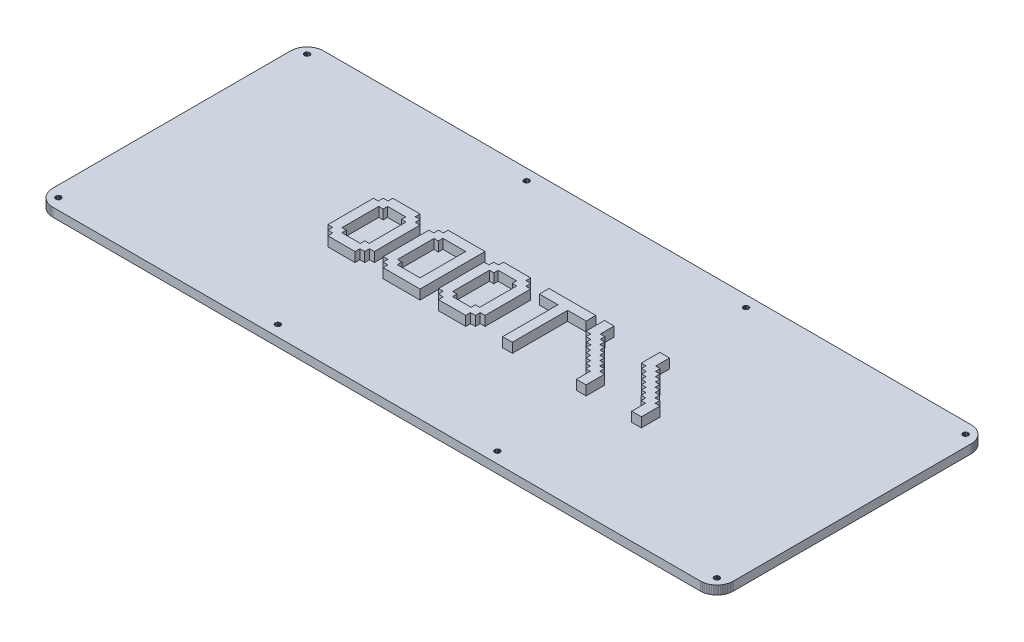
from build123d import *

# Parameters (mm, degrees)
BOSS_EXTRUDE1_DEPTH = 4.7625
BOSS_EXTRUDE3_DEPTH = 10


with BuildPart() as part:
    # Sketch1 → Boss-Extrude1 (new body)
    with BuildSketch(Plane(origin=(0, 0, 0), x_dir=(1, 0, 0), z_dir=(0, 1, 0))):
        Polygon((362.807, 147.967), (363.513, 147.941), (364.215, 147.857), (364.91, 147.719), (365.591, 147.527), (366.254, 147.282), (366.896, 146.987), (367.51, 146.641), (368.099, 146.25), (368.653, 145.812), (369.171, 145.331), (369.651, 144.812), (370.089, 144.259), (370.48, 143.67), (370.826, 143.053), (371.122, 142.412), (371.369, 141.749), (371.56, 141.07), (371.697, 140.375), (371.778, 139.674), (371.807, 138.967), (371.807, 9.09091), (371.778, 8.38535), (371.697, 7.68396), (371.56, 6.99079), (371.369, 6.31003), (371.122, 5.6472), (370.826, 5.00641), (370.48, 4.38905), (370.089, 3.80062), (369.651, 3.24666), (369.171, 2.72852), (368.653, 2.24758), (368.099, 1.81074), (367.51, 1.418), (366.896, 1.07211), (366.254, 0.777215), (365.591, 0.531922), (364.91, 0.340376), (364.215, 0.202572), (363.513, 0.118511), (362.807, 0.0909507), (9.09507, 0.0909507), (8.3881, 0.118511), (7.68671, 0.202572), (6.99216, 0.340376), (6.31278, 0.531922), (5.64995, 0.777215), (5.00916, 1.07211), (4.3918, 1.418), (3.8034, 1.81074), (3.24942, 2.24758), (2.73127, 2.72852), (2.25034, 3.24666), (1.81212, 3.80062), (1.42076, 4.38905), (1.07487, 5.00641), (0.77997, 5.6472), (0.534681, 6.31003), (0.343131, 6.99079), (0.205328, 7.68396), (0.121267, 8.38535), (0.0937066, 9.09228), (0.0950846, 138.967), (0.121267, 139.674), (0.205328, 140.375), (0.343131, 141.07), (0.534681, 141.749), (0.77997, 142.412), (1.07487, 143.053), (1.42076, 143.67), (1.81212, 144.259), (2.25034, 144.812), (2.73127, 145.331), (3.24942, 145.812), (3.8034, 146.25), (4.3918, 146.641), (5.00916, 146.987), (5.64995, 147.282), (6.31278, 147.527), (6.99216, 147.719), (7.68671, 147.857), (8.3881, 147.941), (9.09507, 147.968), align=None)
        Polygon((365.326, 7.51858), (364.917, 7.31188), (364.589, 6.98253), (364.381, 6.57186), (364.307, 6.11572), (364.381, 5.66099), (364.589, 5.25032), (364.917, 4.92372), (365.326, 4.71428), (365.781, 4.64125), (366.24, 4.71428), (366.649, 4.92372), (366.977, 5.25032), (367.185, 5.66099), (367.259, 6.11572), (367.185, 6.57186), (366.977, 6.98253), (366.649, 7.31188), (366.24, 7.51858), (365.781, 7.5916), align=None, mode=Mode.SUBTRACT)
        Polygon((245.438, 7.51858), (245.027, 7.31188), (244.703, 6.98253), (244.492, 6.57186), (244.42, 6.11572), (244.492, 5.66099), (244.703, 5.25032), (245.027, 4.92372), (245.438, 4.71428), (245.894, 4.64125), (246.35, 4.71428), (246.761, 4.92372), (247.088, 5.25032), (247.297, 5.66099), (247.37, 6.11572), (247.297, 6.57186), (247.088, 6.98253), (246.761, 7.31188), (246.35, 7.51858), (245.894, 7.5916), align=None, mode=Mode.SUBTRACT)
        Polygon((125.552, 7.51858), (125.138, 7.31188), (124.815, 6.98253), (124.604, 6.57186), (124.532, 6.11572), (124.604, 5.66099), (124.815, 5.25032), (125.138, 4.92372), (125.552, 4.71428), (126.007, 4.64125), (126.463, 4.71428), (126.873, 4.92372), (127.201, 5.25032), (127.409, 5.66099), (127.482, 6.11572), (127.409, 6.57186), (127.201, 6.98253), (126.873, 7.31188), (126.463, 7.51858), (126.007, 7.5916), align=None, mode=Mode.SUBTRACT)
        Polygon((5.66374, 7.51858), (5.25307, 7.31188), (4.9251, 6.98253), (4.71703, 6.57186), (4.644, 6.11572), (4.71703, 5.66099), (4.9251, 5.25032), (5.25307, 4.92372), (5.66374, 4.71428), (6.11851, 4.64125), (6.57461, 4.71428), (6.98528, 4.92372), (7.31326, 5.25032), (7.52133, 5.66099), (7.59435, 6.11572), (7.52133, 6.57186), (7.31326, 6.98253), (6.98528, 7.31188), (6.57461, 7.51858), (6.11851, 7.5916), align=None, mode=Mode.SUBTRACT)
        Polygon((125.552, 143.345), (125.138, 143.137), (124.815, 142.809), (124.604, 142.398), (124.532, 141.942), (124.604, 141.487), (124.815, 141.077), (125.138, 140.75), (125.552, 140.541), (126.007, 140.468), (126.463, 140.541), (126.873, 140.75), (127.201, 141.077), (127.409, 141.487), (127.482, 141.942), (127.409, 142.398), (127.201, 142.809), (126.873, 143.137), (126.463, 143.345), (126.007, 143.417), align=None, mode=Mode.SUBTRACT)
        Polygon((245.438, 143.345), (245.027, 143.137), (244.703, 142.809), (244.492, 142.398), (244.42, 141.942), (244.492, 141.487), (244.703, 141.077), (245.027, 140.75), (245.438, 140.541), (245.894, 140.468), (246.35, 140.541), (246.761, 140.75), (247.088, 141.077), (247.297, 141.487), (247.37, 141.942), (247.297, 142.398), (247.088, 142.809), (246.761, 143.137), (246.35, 143.345), (245.894, 143.417), align=None, mode=Mode.SUBTRACT)
        Polygon((365.326, 143.345), (364.917, 143.137), (364.589, 142.809), (364.381, 142.398), (364.307, 141.942), (364.381, 141.487), (364.589, 141.077), (364.917, 140.75), (365.326, 140.541), (365.781, 140.468), (366.24, 140.541), (366.649, 140.75), (366.977, 141.077), (367.185, 141.487), (367.259, 141.942), (367.185, 142.398), (366.977, 142.809), (366.649, 143.137), (366.24, 143.345), (365.781, 143.417), align=None, mode=Mode.SUBTRACT)
        Polygon((5.66374, 143.345), (5.25307, 143.137), (4.9251, 142.809), (4.71703, 142.398), (4.644, 141.942), (4.71703, 141.487), (4.9251, 141.077), (5.25307, 140.75), (5.66374, 140.541), (6.11851, 140.468), (6.57461, 140.541), (6.98528, 140.75), (7.31326, 141.077), (7.52133, 141.487), (7.59435, 141.942), (7.52133, 142.398), (7.31326, 142.809), (6.98528, 143.137), (6.57461, 143.345), (6.11851, 143.417), align=None, mode=Mode.SUBTRACT)
    extrude(amount=BOSS_EXTRUDE1_DEPTH)

    # Sketch2 → Boss-Extrude3 (add)
    with BuildSketch(Plane.XZ):
        Polygon((254.071982222, -91.927946148), (248.794955195, -91.927946148), (248.794955195, -81.786159831), (251.433468708, -81.786159831), (251.433468708, -79.252587195), (254.071982222, -79.252587195), (254.071982222, -76.711518783), (256.553084418, -76.711518783), (256.553084418, -74.177946148), (259.026690836, -74.177946148), (259.026690836, -71.644373513), (261.507793032, -71.644373513), (261.507793032, -69.103305101), (263.988895228, -69.103305101), (263.988895228, -66.569732466), (266.462501647, -66.569732466), (266.462501647, -64.036159831), (268.943603843, -64.036159831), (268.943603843, -56.427946148), (274.22063087, -56.427946148), (274.22063087, -66.569732466), (271.582117357, -66.569732466), (271.582117357, -69.103305101), (268.943603843, -69.103305101), (268.943603843, -71.644373513), (266.462501647, -71.644373513), (266.462501647, -74.177946148), (263.988895228, -74.177946148), (263.988895228, -76.711518783), (261.507793032, -76.711518783), (261.507793032, -79.252587195), (259.026690836, -79.252587195), (259.026690836, -81.786159831), (256.553084418, -81.786159831), (256.553084418, -84.319732466), (254.071982222, -84.319732466), align=None)
        Polygon((223.849009249, -91.927946148), (218.571982222, -91.927946148), (218.571982222, -81.786159831), (221.210495735, -81.786159831), (221.210495735, -79.252587195), (223.849009249, -79.252587195), (223.849009249, -76.711518783), (226.330111445, -76.711518783), (226.330111445, -74.177946148), (228.803717864, -74.177946148), (228.803717864, -71.644373513), (231.284820059, -71.644373513), (231.284820059, -69.103305101), (233.765922255, -69.103305101), (233.765922255, -66.569732466), (236.239528674, -66.569732466), (236.239528674, -64.036159831), (238.72063087, -64.036159831), (238.72063087, -56.427946148), (243.997657897, -56.427946148), (243.997657897, -66.569732466), (241.359144384, -66.569732466), (241.359144384, -69.103305101), (238.72063087, -69.103305101), (238.72063087, -71.644373513), (236.239528674, -71.644373513), (236.239528674, -74.177946148), (233.765922255, -74.177946148), (233.765922255, -76.711518783), (231.284820059, -76.711518783), (231.284820059, -79.252587195), (228.803717864, -79.252587195), (228.803717864, -81.786159831), (226.330111445, -81.786159831), (226.330111445, -84.319732466), (223.849009249, -84.319732466), align=None)
        Polygon((203.7003606, -86.650919121), (213.819659586, -86.650919121), (213.819659586, -91.927946148), (188.304034586, -91.927946148), (188.304034586, -86.650919121), (198.423333573, -86.650919121), (198.423333573, -56.427946148), (203.7003606, -56.427946148), align=None)
        Polygon((178.274684924, -89.289432635), (178.274684924, -91.927946148), (163.403063303, -91.927946148), (163.403063303, -89.289432635), (160.764549789, -89.289432635), (160.764549789, -86.650919121), (158.126036276, -86.650919121), (158.126036276, -61.704973175), (160.764549789, -61.704973175), (160.764549789, -59.066459662), (163.403063303, -59.066459662), (163.403063303, -56.427946148), (178.274684924, -56.427946148), (178.274684924, -59.066459662), (180.913198438, -59.066459662), (180.913198438, -61.704973175), (183.551711951, -61.704973175), (183.551711951, -86.650919121), (180.913198438, -86.650919121), (180.913198438, -89.289432635), align=None)
        Polygon((165.801711951, -86.650919121), (175.876036276, -86.650919121), (175.876036276, -84.252270472), (178.274684924, -84.252270472), (178.274684924, -64.103621824), (175.876036276, -64.103621824), (175.876036276, -61.704973175), (165.801711951, -61.704973175), (165.801711951, -64.103621824), (163.403063303, -64.103621824), (163.403063303, -84.252270472), (165.801711951, -84.252270472), align=None, mode=Mode.SUBTRACT)
        Polygon((153.328738978, -56.427946148), (153.328738978, -91.927946148), (133.18009033, -91.927946148), (133.18009033, -89.289432635), (130.541576816, -89.289432635), (130.541576816, -86.650919121), (127.903063303, -86.650919121), (127.903063303, -61.704973175), (130.541576816, -61.704973175), (130.541576816, -59.066459662), (133.18009033, -59.066459662), (133.18009033, -56.427946148), align=None)
        Polygon((148.051711951, -86.650919121), (148.051711951, -61.704973175), (135.578738978, -61.704973175), (135.578738978, -64.201066925), (133.18009033, -64.201066925), (133.18009033, -84.154825371), (135.578738978, -84.154825371), (135.578738978, -86.650919121), align=None, mode=Mode.SUBTRACT)
        Polygon((117.828738978, -89.289432635), (117.828738978, -91.927946148), (102.957117357, -91.927946148), (102.957117357, -89.289432635), (100.318603843, -89.289432635), (100.318603843, -86.650919121), (97.68009033, -86.650919121), (97.68009033, -61.704973175), (100.318603843, -61.704973175), (100.318603843, -59.066459662), (102.957117357, -59.066459662), (102.957117357, -56.427946148), (117.828738978, -56.427946148), (117.828738978, -59.066459662), (120.467252492, -59.066459662), (120.467252492, -61.704973175), (123.105766005, -61.704973175), (123.105766005, -86.650919121), (120.467252492, -86.650919121), (120.467252492, -89.289432635), align=None)
        Polygon((105.355766005, -86.650919121), (115.43009033, -86.650919121), (115.43009033, -84.252270472), (117.828738978, -84.252270472), (117.828738978, -64.103621824), (115.43009033, -64.103621824), (115.43009033, -61.704973175), (105.355766005, -61.704973175), (105.355766005, -64.103621824), (102.957117357, -64.103621824), (102.957117357, -84.252270472), (105.355766005, -84.252270472), align=None, mode=Mode.SUBTRACT)
    extrude(amount=-BOSS_EXTRUDE3_DEPTH)


solid = part.part
